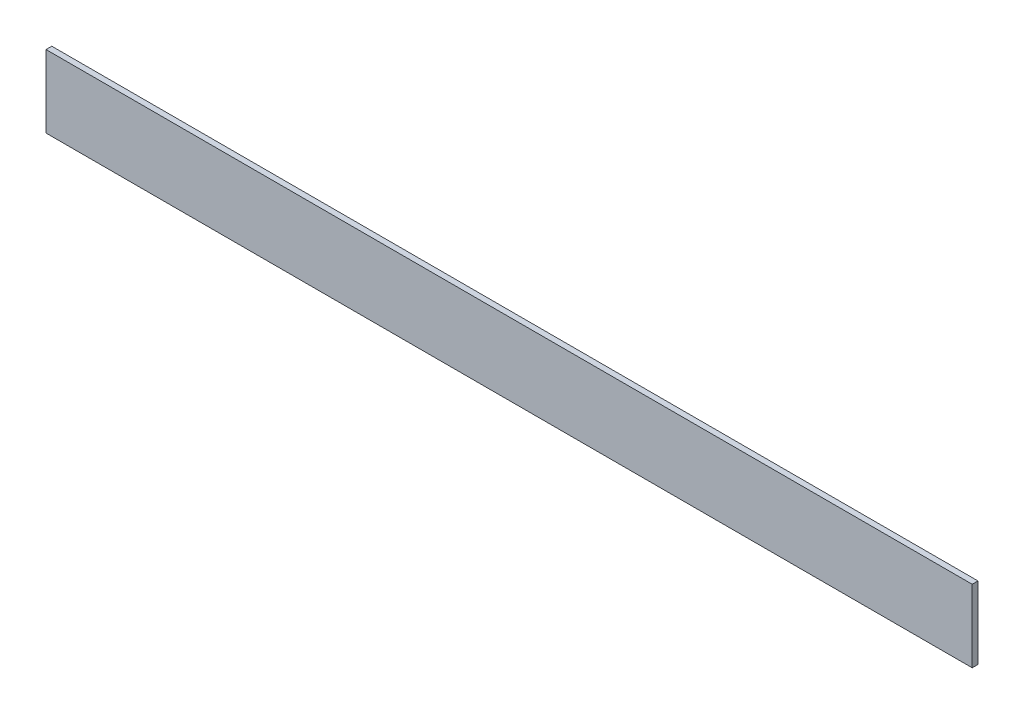
from build123d import *

# Parameters (mm, degrees)
EXTRUDE_1_DEPTH     = 320
SKETCH_2_W          = 23
SKETCH_2_H          = 23
CUT_EXTRUDE_1_DEPTH = 26


with BuildPart() as part:
    # Эскиз1 → Вытянуть-Тонкостенный1 (new body)
    with BuildSketch(Plane(origin=(0, 0, 0), x_dir=(0, 0, -1), z_dir=(1, 0, 0))):
        Polygon((0, 25), (0, 0), (25, 0), (25, 2), (2, 2), (2, 25), align=None)
    extrude(amount=EXTRUDE_1_DEPTH)

    # Эскиз2 → Вырез-Вытянуть1 (cut, through all)
    with BuildSketch(Plane.XZ):
        with Locations((308.5, -13.5)):
            Rectangle(SKETCH_2_W, SKETCH_2_H)
    extrude(amount=-CUT_EXTRUDE_1_DEPTH, mode=Mode.SUBTRACT)


solid = part.part
